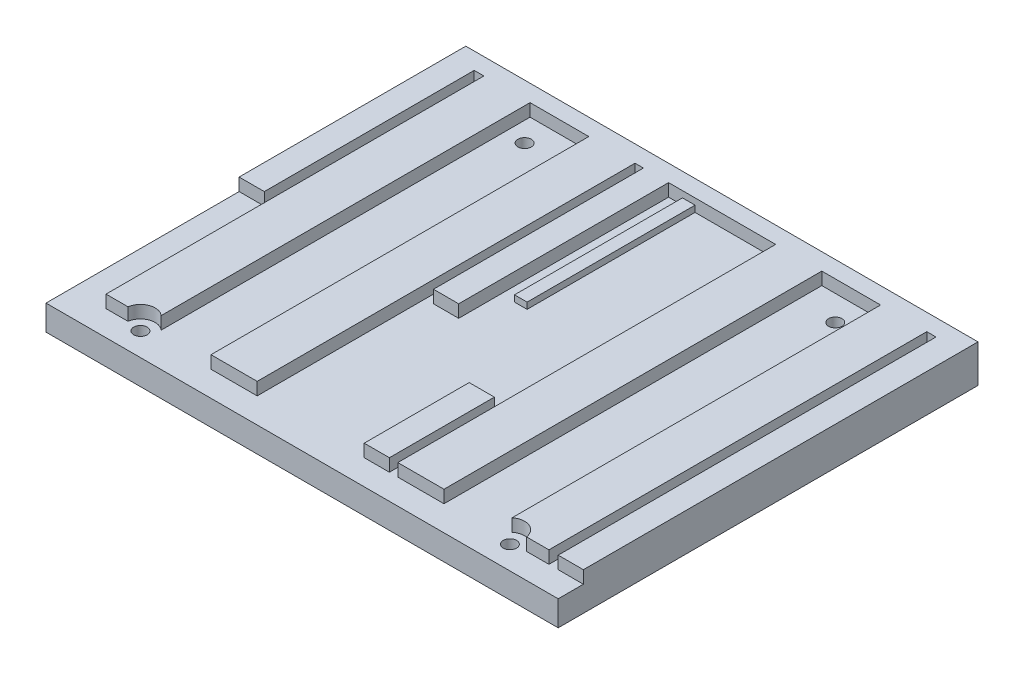
from build123d import *

# Parameters (mm, degrees)
SKETCH1_W                   = 122
SKETCH1_H                   = 100
BOSS_EXTRUDE1_DEPTH         = 3
SKETCH2_W                   = 6
SKETCH2_H                   = 50
SKETCH2_W_2                 = 11
SKETCH2_H_2                 = 90
SKETCH2_H_3                 = 25
BOSS_EXTRUDE2_DEPTH         = 3
SKETCH3_W                   = 3
SKETCH3_H                   = 40
BOSS_EXTRUDE3_DEPTH         = 1.5
SKETCH4_W                   = 122
SKETCH4_H                   = 4
BOSS_EXTRUDE4_DEPTH         = 3
SKETCH7_W                   = 122
SKETCH7_H                   = 100
BOSS_EXTRUDE5_DEPTH         = 3
SKETCH5_R                   = 1.6
STANDOFF_HOLE_DEPTH         = 4
STANDOFF_HOLE_DEPTH_BACK    = 7
SKETCH6_R                   = 3.5
CLEARANCE_HOLE_TOP_DEPTH    = 4
SKETCH8_R                   = 3.5
CLEARANCE_HOLE_BOTTOM_DEPTH = 3


with BuildPart() as part:
    # Sketch1 → Boss-Extrude1 (new body)
    with BuildSketch(Plane(origin=(0, 0, 0), x_dir=(1, 0, 0), z_dir=(0, 1, 0))):
        with Locations((61, 50)):
            Rectangle(SKETCH1_W, SKETCH1_H)
    extrude(amount=BOSS_EXTRUDE1_DEPTH)

    # Sketch2 → Boss-Extrude2 (add)
    with BuildSketch(Plane(origin=(0, 3, 0), x_dir=(1, 0, 0), z_dir=(0, 1, 0))):
        with Locations((3, 71)):
            Rectangle(SKETCH2_W, SKETCH2_H)
        with Locations((13.8, 51)):
            Rectangle(SKETCH2_W_2, SKETCH2_H_2)
        with Locations((38.8, 51)):
            Rectangle(SKETCH2_W_2, SKETCH2_H_2)
        with Locations((49.3, 71)):
            Rectangle(SKETCH2_W, SKETCH2_H)
        with Locations((72.8, 18.5)):
            Rectangle(SKETCH2_W, SKETCH2_H_3)
        with Locations((83.3, 51)):
            Rectangle(SKETCH2_W_2, SKETCH2_H_2)
        with Locations((108.3, 51)):
            Rectangle(SKETCH2_W_2, SKETCH2_H_2)
        with Locations((119, 51)):
            Rectangle(SKETCH2_W, SKETCH2_H_2)
    extrude(amount=BOSS_EXTRUDE2_DEPTH)

    # Sketch3 → Boss-Extrude3 (add)
    with BuildSketch(Plane(origin=(0, 3, 0), x_dir=(1, 0, 0), z_dir=(0, 1, 0))):
        with Locations((57.1, 76)):
            Rectangle(SKETCH3_W, SKETCH3_H)
    extrude(amount=BOSS_EXTRUDE3_DEPTH)

    # Sketch4 → Boss-Extrude4 (add)
    with BuildSketch(Plane(origin=(0, 3, 0), x_dir=(1, 0, 0), z_dir=(0, 1, 0))):
        with Locations((61, 98)):
            Rectangle(SKETCH4_W, SKETCH4_H)
    extrude(amount=BOSS_EXTRUDE4_DEPTH)

    # Sketch7 → Boss-Extrude5 (add)
    with BuildSketch(Plane.XZ):
        with Locations((61, -50)):
            Rectangle(SKETCH7_W, SKETCH7_H)
    extrude(amount=BOSS_EXTRUDE5_DEPTH)

    # Sketch5 → standoff hole (cut, two sides)
    with BuildSketch(Plane(origin=(0, 3, 0), x_dir=(1, 0, 0), z_dir=(0, 1, 0))) as standoff_hole_sk:
        with Locations((17, 5.5)):
            Circle(SKETCH5_R)
        with Locations((105, 5.5)):
            Circle(SKETCH5_R)
        with Locations((24, 90)):
            Circle(SKETCH5_R)
        with Locations((98, 90)):
            Circle(SKETCH5_R)
    extrude(amount=STANDOFF_HOLE_DEPTH, mode=Mode.SUBTRACT)
    extrude(standoff_hole_sk.sketch, amount=-STANDOFF_HOLE_DEPTH_BACK, mode=Mode.SUBTRACT)

    # Sketch6 → clearance hole top (cut, through all)
    with BuildSketch(Plane(origin=(0, 3, 0), x_dir=(1, 0, 0), z_dir=(0, 1, 0))):
        with Locations((17, 5.5)):
            Circle(SKETCH6_R)
        with Locations((105, 5.5)):
            Circle(SKETCH6_R)
    extrude(amount=CLEARANCE_HOLE_TOP_DEPTH, mode=Mode.SUBTRACT)

    # Sketch8 → clearance hole bottom (cut)
    with BuildSketch(Plane.XZ.offset(3)):
        with Locations((17, -5.5)):
            Circle(SKETCH8_R)
        with Locations((105, -5.5)):
            Circle(SKETCH8_R)
        with Locations((98, -90)):
            Circle(SKETCH8_R)
        with Locations((24, -90)):
            Circle(SKETCH8_R)
    extrude(amount=-CLEARANCE_HOLE_BOTTOM_DEPTH, mode=Mode.SUBTRACT)


solid = part.part
